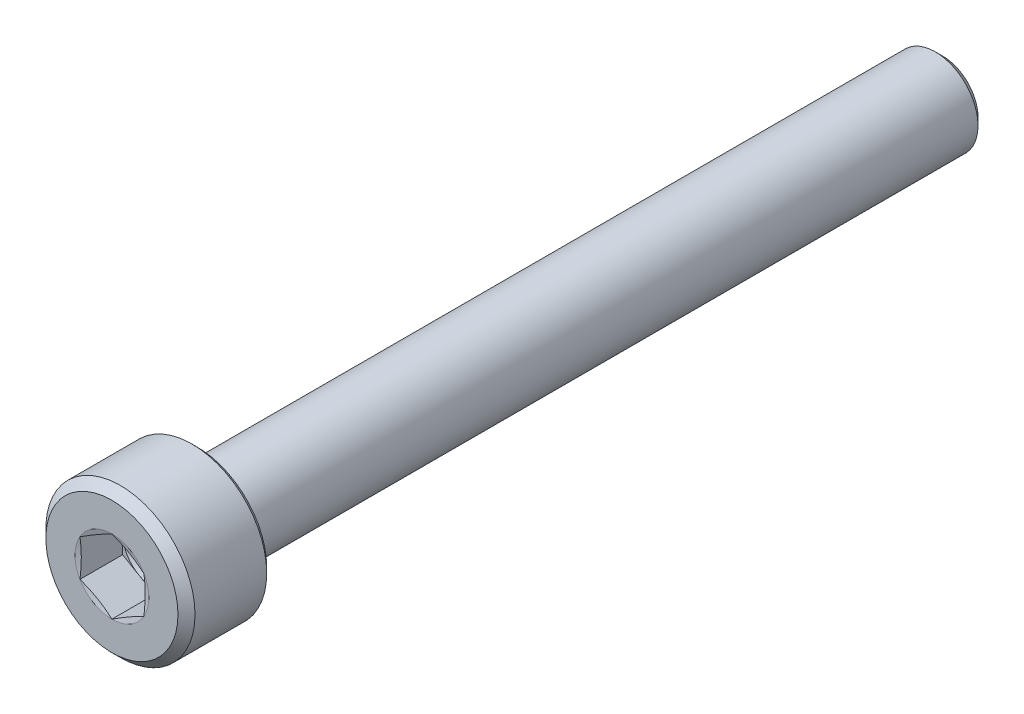
from build123d import *

# Parameters (mm, degrees)
CUT_EXTRUDE1_DEPTH = 2


with BuildPart() as part:
    # Sketch1 → Revolve1 (revolve)
    with BuildSketch(Plane(origin=(0, 0, 0), x_dir=(0, 0, -1), z_dir=(1, 0, 0))):
        with BuildLine():
            Line((0, 0), (0, 3.1))
            Line((0, 3.1), (0.4, 3.5))
            Line((0.4, 3.5), (3.765, 3.5))
            Line((3.765, 3.5), (4, 3.265))
            Line((4, 3.265), (4, 2.35))
            ThreePointArc((4, 2.35), (4.035614876, 2.236081032), (4.129775312, 2.162734164))
            Line((4.129775312, 2.162734164), (4.529775312, 2.012734164))
            ThreePointArc((4.529775312, 2.012734164), (4.564315039, 2.00320929), (4.6, 2))
            Line((4.6, 2), (38.65, 2))
            Line((38.65, 2), (39, 1.65))
            Line((39, 1.65), (39, 0))
            Line((39, 0), (0, 0))
        make_face()
    revolve(axis=Axis((0, 0, 0), (0, 0, -1)))

    # Sketch2 → Cut-Extrude1 (cut)
    with BuildSketch(Plane.XY):
        Polygon((0, 1.732050808), (-1.5, 0.866025404), (-1.5, -0.866025404), (0, -1.732050808), (1.5, -0.866025404), (1.5, 0.866025404), align=None)
    extrude(amount=-CUT_EXTRUDE1_DEPTH, mode=Mode.SUBTRACT)

    # Sketch3 → Cut-Revolve2 (revolve, cut)
    with BuildSketch(Plane(origin=(0, 0, 0), x_dir=(0, 0, -1), z_dir=(1, 0, 0))):
        Polygon((2, 0), (2, 1.5), (2.866025404, 0), align=None)
    revolve(axis=Axis((0, 0, -2), (0, 0, -1)), mode=Mode.SUBTRACT)

    # Sketch4 → Cut-Revolve3 (revolve, cut)
    with BuildSketch(Plane(origin=(0, 0, 0), x_dir=(0, 0, -1), z_dir=(1, 0, 0))):
        Polygon((0, 1.732050808), (0, 1.5), (0.062177826, 1.5), align=None)
    revolve(axis=Axis((0, 0, 0), (0, 0, -1)), mode=Mode.SUBTRACT)


solid = part.part
